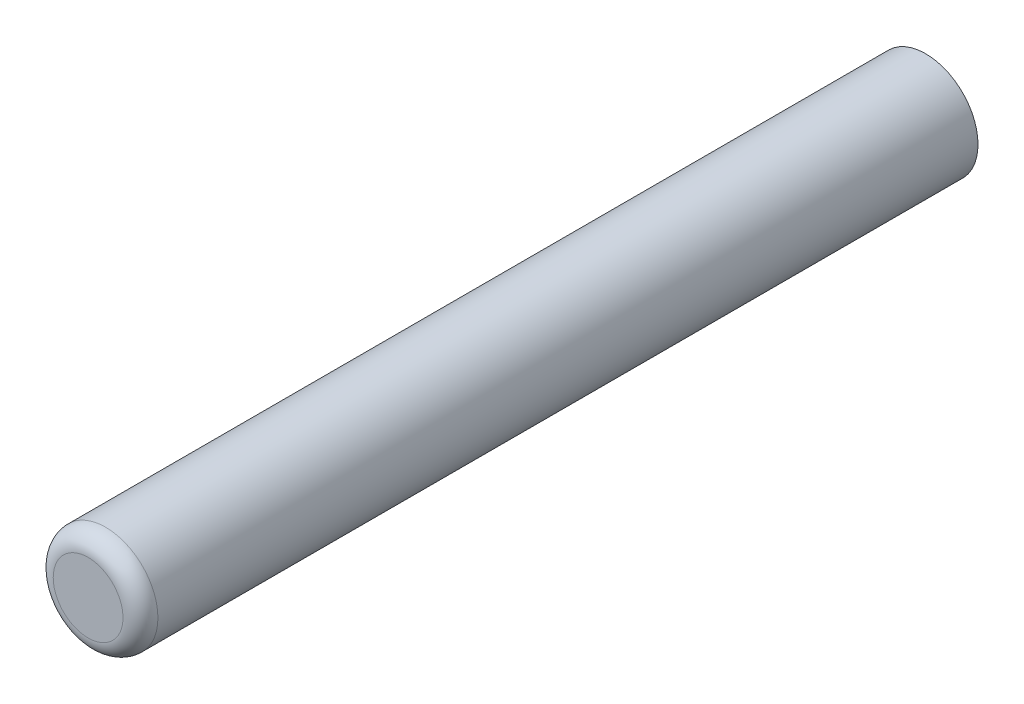
from build123d import *

# Parameters (mm, degrees)
SKETCH2_W = 76.2
SKETCH2_H = 4.7625
FILLET1_R = 1.5875


with BuildPart() as part:
    # Sketch2 → Revolve1 (revolve)
    with BuildSketch(Plane(origin=(0, 0, 0), x_dir=(0, 0, -1), z_dir=(1, 0, 0))):
        with Locations((38.1, 2.38125)):
            Rectangle(SKETCH2_W, SKETCH2_H)
    revolve(axis=Axis((0, 0, 0), (0, 0, -1)))

    # Fillet1
    fillet1_edges = [part.edges().sort_by_distance(p)[0] for p in [
        (0, -4.7625, 0),
    ]]
    fillet(fillet1_edges, radius=FILLET1_R)


solid = part.part
